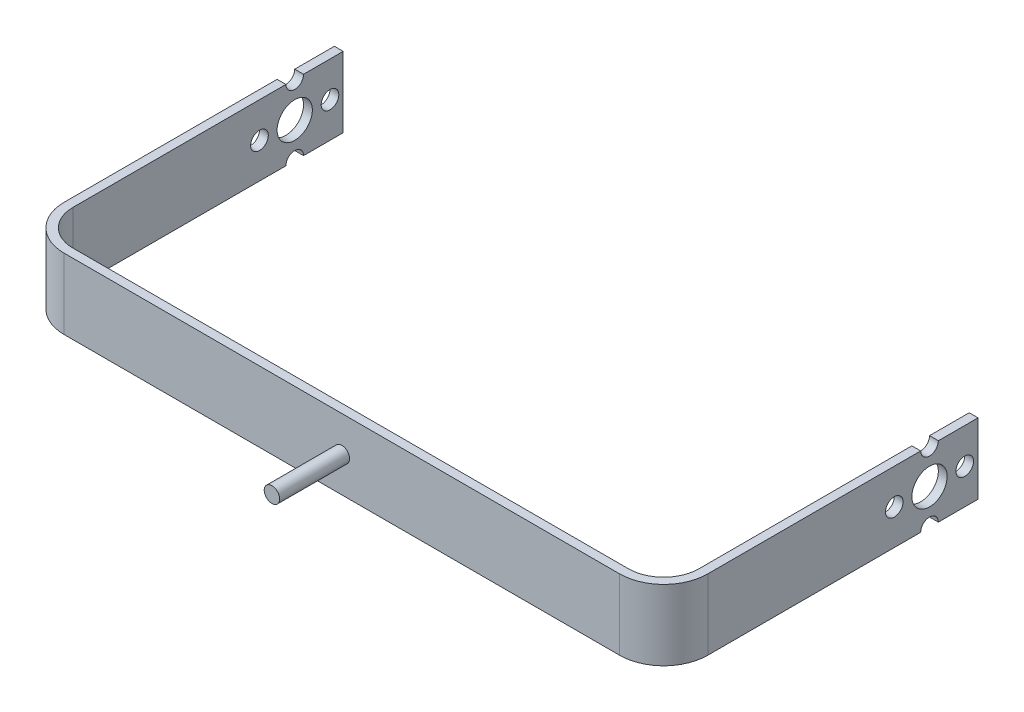
from build123d import *

# Parameters (mm, degrees)
BOSS_EXTRUDE1_DEPTH = 16
FILLET1_R           = 8
FILLET2_R           = 10
SKETCH2_R           = 4
SKETCH2_R_2         = 2
CUT_EXTRUDE1_DEPTH  = 147.05
SKETCH3_R           = 1.75
BOSS_EXTRUDE2_DEPTH = 15.875


with BuildPart() as part:
    # Sketch1 → Boss-Extrude1 (new body)
    with BuildSketch(Plane(origin=(0, 0, 0), x_dir=(1, 0, 0), z_dir=(0, 1, 0))):
        Polygon((0, 0), (142.05, 0), (142.05, 69.325), (144.05, 69.325), (144.05, -2), (-2, -2), (-2, 69.325), (0, 69.325), align=None)
    extrude(amount=BOSS_EXTRUDE1_DEPTH)

    # Fillet1
    fillet1_edges = [part.edges().sort_by_distance(p)[0] for p in [
        (0, 8, 0),
        (142.05, 8, 0),
    ]]
    fillet(fillet1_edges, radius=FILLET1_R)

    # Fillet2
    fillet2_edges = [part.edges().sort_by_distance(p)[0] for p in [
        (144.05, 8, 2),
        (-2, 8, 2),
    ]]
    fillet(fillet2_edges, radius=FILLET2_R)

    # Sketch2 → Cut-Extrude1 (cut, through all)
    with BuildSketch(Plane(origin=(144.05, 0, 0), x_dir=(0, 0, -1), z_dir=(1, 0, 0))):
        with Locations((58.325, 8)):
            Circle(SKETCH2_R)
        with Locations((66.325, 8)):
            Circle(SKETCH2_R_2)
        with Locations((58.325, 0)):
            Circle(SKETCH2_R_2)
        with Locations((50.325, 8)):
            Circle(SKETCH2_R_2)
        with Locations((58.325, 16)):
            Circle(SKETCH2_R_2)
    extrude(amount=-CUT_EXTRUDE1_DEPTH, mode=Mode.SUBTRACT)

    # Sketch3 → Boss-Extrude2 (add)
    with BuildSketch(Plane.XY.offset(2)):
        with Locations((71.025, 8)):
            Circle(SKETCH3_R)
    extrude(amount=BOSS_EXTRUDE2_DEPTH)


solid = part.part
